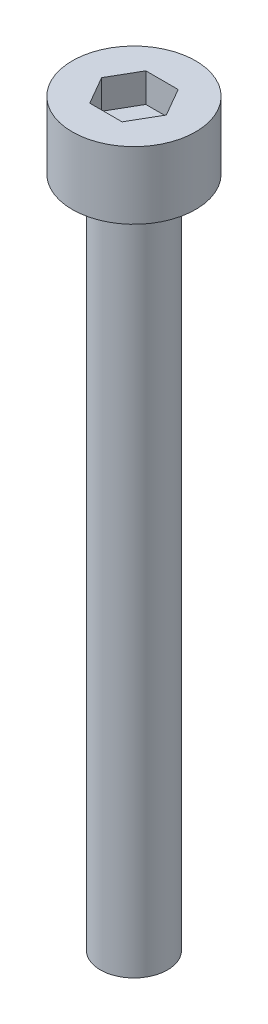
from build123d import *

# Parameters (mm, degrees)
SKETCH_1_R            = 2.75
EXTRUDE_248_DEPTH     = 3
CUT_EXTRUDE_378_DEPTH = 1.3
SKETCH_3_R            = 1.5
EXTRUDE_479_DEPTH     = 30


with BuildPart() as part:
    # 草图1 → Extrude 248 (new body)
    with BuildSketch(Plane(origin=(0, 0, 0), x_dir=(1, 0, 0), z_dir=(0, 1, 0))):
        Circle(SKETCH_1_R)
    extrude(amount=EXTRUDE_248_DEPTH)

    # 草图2 → Cut-Extrude 378 (cut)
    with BuildSketch(Plane(origin=(0, 3, 0), x_dir=(1, 0, 0), z_dir=(0, 1, 0))):
        Polygon((1.443375673, 0), (0.721687836, 1.25), (-0.721687836, 1.25), (-1.443375673, 0), (-0.721687836, -1.25), (0.721687836, -1.25), align=None)
    extrude(amount=-CUT_EXTRUDE_378_DEPTH, mode=Mode.SUBTRACT)

    # 草图3 → Extrude 479 (add)
    with BuildSketch(Plane.XZ):
        Circle(SKETCH_3_R)
    extrude(amount=EXTRUDE_479_DEPTH)


solid = part.part
